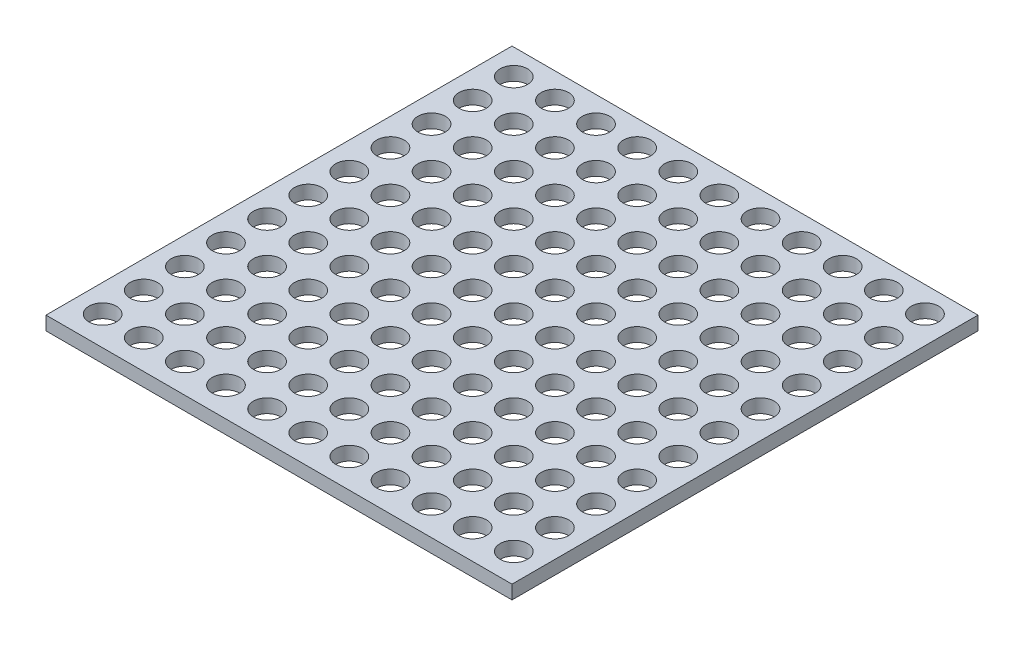
from build123d import *

# Parameters (mm, degrees)
SKETCH1_W           = 107.95
SKETCH1_H           = 107.95
SKETCH1_R           = 3.175
BOSS_EXTRUDE1_DEPTH = 3.175


with BuildPart() as part:
    # Sketch1 → Boss-Extrude1 (new body)
    with BuildSketch(Plane(origin=(0, 0, 0), x_dir=(1, 0, 0), z_dir=(0, 1, 0))):
        with Locations((53.975, 55.266525424)):
            Rectangle(SKETCH1_W, SKETCH1_H)
        with Locations((6.35, 8.056512099)):
            Circle(SKETCH1_R, mode=Mode.SUBTRACT)
        with Locations((15.875, 8.056512099)):
            Circle(SKETCH1_R, mode=Mode.SUBTRACT)
        with Locations((25.4, 8.056512099)):
            Circle(SKETCH1_R, mode=Mode.SUBTRACT)
        with Locations((34.925, 8.056512099)):
            Circle(SKETCH1_R, mode=Mode.SUBTRACT)
        with Locations((44.45, 8.056512099)):
            Circle(SKETCH1_R, mode=Mode.SUBTRACT)
        with Locations((53.975, 8.056512099)):
            Circle(SKETCH1_R, mode=Mode.SUBTRACT)
        with Locations((63.5, 8.056512099)):
            Circle(SKETCH1_R, mode=Mode.SUBTRACT)
        with Locations((73.025, 8.056512099)):
            Circle(SKETCH1_R, mode=Mode.SUBTRACT)
        with Locations((82.55, 8.056512099)):
            Circle(SKETCH1_R, mode=Mode.SUBTRACT)
        with Locations((92.075, 8.056512099)):
            Circle(SKETCH1_R, mode=Mode.SUBTRACT)
        with Locations((101.6, 8.056512099)):
            Circle(SKETCH1_R, mode=Mode.SUBTRACT)
        with Locations((101.6, 17.581512099)):
            Circle(SKETCH1_R, mode=Mode.SUBTRACT)
        with Locations((92.075, 17.581512099)):
            Circle(SKETCH1_R, mode=Mode.SUBTRACT)
        with Locations((82.55, 17.581512099)):
            Circle(SKETCH1_R, mode=Mode.SUBTRACT)
        with Locations((73.025, 17.581512099)):
            Circle(SKETCH1_R, mode=Mode.SUBTRACT)
        with Locations((63.5, 17.581512099)):
            Circle(SKETCH1_R, mode=Mode.SUBTRACT)
        with Locations((53.975, 17.581512099)):
            Circle(SKETCH1_R, mode=Mode.SUBTRACT)
        with Locations((44.45, 17.581512099)):
            Circle(SKETCH1_R, mode=Mode.SUBTRACT)
        with Locations((34.925, 17.581512099)):
            Circle(SKETCH1_R, mode=Mode.SUBTRACT)
        with Locations((25.4, 17.581512099)):
            Circle(SKETCH1_R, mode=Mode.SUBTRACT)
        with Locations((15.875, 17.581512099)):
            Circle(SKETCH1_R, mode=Mode.SUBTRACT)
        with Locations((6.35, 17.581512099)):
            Circle(SKETCH1_R, mode=Mode.SUBTRACT)
        with Locations((101.6, 27.106512099)):
            Circle(SKETCH1_R, mode=Mode.SUBTRACT)
        with Locations((92.075, 27.106512099)):
            Circle(SKETCH1_R, mode=Mode.SUBTRACT)
        with Locations((82.55, 27.106512099)):
            Circle(SKETCH1_R, mode=Mode.SUBTRACT)
        with Locations((73.025, 27.106512099)):
            Circle(SKETCH1_R, mode=Mode.SUBTRACT)
        with Locations((63.5, 27.106512099)):
            Circle(SKETCH1_R, mode=Mode.SUBTRACT)
        with Locations((53.975, 27.106512099)):
            Circle(SKETCH1_R, mode=Mode.SUBTRACT)
        with Locations((44.45, 27.106512099)):
            Circle(SKETCH1_R, mode=Mode.SUBTRACT)
        with Locations((34.925, 27.106512099)):
            Circle(SKETCH1_R, mode=Mode.SUBTRACT)
        with Locations((25.4, 27.106512099)):
            Circle(SKETCH1_R, mode=Mode.SUBTRACT)
        with Locations((15.875, 27.106512099)):
            Circle(SKETCH1_R, mode=Mode.SUBTRACT)
        with Locations((6.35, 27.106512099)):
            Circle(SKETCH1_R, mode=Mode.SUBTRACT)
        with Locations((101.6, 36.631512099)):
            Circle(SKETCH1_R, mode=Mode.SUBTRACT)
        with Locations((92.075, 36.631512099)):
            Circle(SKETCH1_R, mode=Mode.SUBTRACT)
        with Locations((82.55, 36.631512099)):
            Circle(SKETCH1_R, mode=Mode.SUBTRACT)
        with Locations((73.025, 36.631512099)):
            Circle(SKETCH1_R, mode=Mode.SUBTRACT)
        with Locations((63.5, 36.631512099)):
            Circle(SKETCH1_R, mode=Mode.SUBTRACT)
        with Locations((53.975, 36.631512099)):
            Circle(SKETCH1_R, mode=Mode.SUBTRACT)
        with Locations((44.45, 36.631512099)):
            Circle(SKETCH1_R, mode=Mode.SUBTRACT)
        with Locations((34.925, 36.631512099)):
            Circle(SKETCH1_R, mode=Mode.SUBTRACT)
        with Locations((25.4, 36.631512099)):
            Circle(SKETCH1_R, mode=Mode.SUBTRACT)
        with Locations((15.875, 36.631512099)):
            Circle(SKETCH1_R, mode=Mode.SUBTRACT)
        with Locations((6.35, 36.631512099)):
            Circle(SKETCH1_R, mode=Mode.SUBTRACT)
        with Locations((101.6, 46.156512099)):
            Circle(SKETCH1_R, mode=Mode.SUBTRACT)
        with Locations((92.075, 46.156512099)):
            Circle(SKETCH1_R, mode=Mode.SUBTRACT)
        with Locations((82.55, 46.156512099)):
            Circle(SKETCH1_R, mode=Mode.SUBTRACT)
        with Locations((73.025, 46.156512099)):
            Circle(SKETCH1_R, mode=Mode.SUBTRACT)
        with Locations((63.5, 46.156512099)):
            Circle(SKETCH1_R, mode=Mode.SUBTRACT)
        with Locations((53.975, 46.156512099)):
            Circle(SKETCH1_R, mode=Mode.SUBTRACT)
        with Locations((44.45, 46.156512099)):
            Circle(SKETCH1_R, mode=Mode.SUBTRACT)
        with Locations((34.925, 46.156512099)):
            Circle(SKETCH1_R, mode=Mode.SUBTRACT)
        with Locations((25.4, 46.156512099)):
            Circle(SKETCH1_R, mode=Mode.SUBTRACT)
        with Locations((15.875, 46.156512099)):
            Circle(SKETCH1_R, mode=Mode.SUBTRACT)
        with Locations((6.35, 46.156512099)):
            Circle(SKETCH1_R, mode=Mode.SUBTRACT)
        with Locations((101.6, 55.681512099)):
            Circle(SKETCH1_R, mode=Mode.SUBTRACT)
        with Locations((92.075, 55.681512099)):
            Circle(SKETCH1_R, mode=Mode.SUBTRACT)
        with Locations((82.55, 55.681512099)):
            Circle(SKETCH1_R, mode=Mode.SUBTRACT)
        with Locations((73.025, 55.681512099)):
            Circle(SKETCH1_R, mode=Mode.SUBTRACT)
        with Locations((63.5, 55.681512099)):
            Circle(SKETCH1_R, mode=Mode.SUBTRACT)
        with Locations((53.975, 55.681512099)):
            Circle(SKETCH1_R, mode=Mode.SUBTRACT)
        with Locations((44.45, 55.681512099)):
            Circle(SKETCH1_R, mode=Mode.SUBTRACT)
        with Locations((34.925, 55.681512099)):
            Circle(SKETCH1_R, mode=Mode.SUBTRACT)
        with Locations((25.4, 55.681512099)):
            Circle(SKETCH1_R, mode=Mode.SUBTRACT)
        with Locations((15.875, 55.681512099)):
            Circle(SKETCH1_R, mode=Mode.SUBTRACT)
        with Locations((6.35, 55.681512099)):
            Circle(SKETCH1_R, mode=Mode.SUBTRACT)
        with Locations((101.6, 65.206512099)):
            Circle(SKETCH1_R, mode=Mode.SUBTRACT)
        with Locations((92.075, 65.206512099)):
            Circle(SKETCH1_R, mode=Mode.SUBTRACT)
        with Locations((82.55, 65.206512099)):
            Circle(SKETCH1_R, mode=Mode.SUBTRACT)
        with Locations((73.025, 65.206512099)):
            Circle(SKETCH1_R, mode=Mode.SUBTRACT)
        with Locations((63.5, 65.206512099)):
            Circle(SKETCH1_R, mode=Mode.SUBTRACT)
        with Locations((53.975, 65.206512099)):
            Circle(SKETCH1_R, mode=Mode.SUBTRACT)
        with Locations((44.45, 65.206512099)):
            Circle(SKETCH1_R, mode=Mode.SUBTRACT)
        with Locations((34.925, 65.206512099)):
            Circle(SKETCH1_R, mode=Mode.SUBTRACT)
        with Locations((25.4, 65.206512099)):
            Circle(SKETCH1_R, mode=Mode.SUBTRACT)
        with Locations((15.875, 65.206512099)):
            Circle(SKETCH1_R, mode=Mode.SUBTRACT)
        with Locations((6.35, 65.206512099)):
            Circle(SKETCH1_R, mode=Mode.SUBTRACT)
        with Locations((101.6, 74.731512099)):
            Circle(SKETCH1_R, mode=Mode.SUBTRACT)
        with Locations((92.075, 74.731512099)):
            Circle(SKETCH1_R, mode=Mode.SUBTRACT)
        with Locations((82.55, 74.731512099)):
            Circle(SKETCH1_R, mode=Mode.SUBTRACT)
        with Locations((73.025, 74.731512099)):
            Circle(SKETCH1_R, mode=Mode.SUBTRACT)
        with Locations((63.5, 74.731512099)):
            Circle(SKETCH1_R, mode=Mode.SUBTRACT)
        with Locations((53.975, 74.731512099)):
            Circle(SKETCH1_R, mode=Mode.SUBTRACT)
        with Locations((44.45, 74.731512099)):
            Circle(SKETCH1_R, mode=Mode.SUBTRACT)
        with Locations((34.925, 74.731512099)):
            Circle(SKETCH1_R, mode=Mode.SUBTRACT)
        with Locations((25.4, 74.731512099)):
            Circle(SKETCH1_R, mode=Mode.SUBTRACT)
        with Locations((15.875, 74.731512099)):
            Circle(SKETCH1_R, mode=Mode.SUBTRACT)
        with Locations((6.35, 74.731512099)):
            Circle(SKETCH1_R, mode=Mode.SUBTRACT)
        with Locations((101.6, 84.256512099)):
            Circle(SKETCH1_R, mode=Mode.SUBTRACT)
        with Locations((92.075, 84.256512099)):
            Circle(SKETCH1_R, mode=Mode.SUBTRACT)
        with Locations((82.55, 84.256512099)):
            Circle(SKETCH1_R, mode=Mode.SUBTRACT)
        with Locations((73.025, 84.256512099)):
            Circle(SKETCH1_R, mode=Mode.SUBTRACT)
        with Locations((63.5, 84.256512099)):
            Circle(SKETCH1_R, mode=Mode.SUBTRACT)
        with Locations((53.975, 84.256512099)):
            Circle(SKETCH1_R, mode=Mode.SUBTRACT)
        with Locations((44.45, 84.256512099)):
            Circle(SKETCH1_R, mode=Mode.SUBTRACT)
        with Locations((34.925, 84.256512099)):
            Circle(SKETCH1_R, mode=Mode.SUBTRACT)
        with Locations((25.4, 84.256512099)):
            Circle(SKETCH1_R, mode=Mode.SUBTRACT)
        with Locations((15.875, 84.256512099)):
            Circle(SKETCH1_R, mode=Mode.SUBTRACT)
        with Locations((6.35, 84.256512099)):
            Circle(SKETCH1_R, mode=Mode.SUBTRACT)
        with Locations((101.6, 93.781512099)):
            Circle(SKETCH1_R, mode=Mode.SUBTRACT)
        with Locations((92.075, 93.781512099)):
            Circle(SKETCH1_R, mode=Mode.SUBTRACT)
        with Locations((82.55, 93.781512099)):
            Circle(SKETCH1_R, mode=Mode.SUBTRACT)
        with Locations((73.025, 93.781512099)):
            Circle(SKETCH1_R, mode=Mode.SUBTRACT)
        with Locations((63.5, 93.781512099)):
            Circle(SKETCH1_R, mode=Mode.SUBTRACT)
        with Locations((53.975, 93.781512099)):
            Circle(SKETCH1_R, mode=Mode.SUBTRACT)
        with Locations((44.45, 93.781512099)):
            Circle(SKETCH1_R, mode=Mode.SUBTRACT)
        with Locations((34.925, 93.781512099)):
            Circle(SKETCH1_R, mode=Mode.SUBTRACT)
        with Locations((25.4, 93.781512099)):
            Circle(SKETCH1_R, mode=Mode.SUBTRACT)
        with Locations((15.875, 93.781512099)):
            Circle(SKETCH1_R, mode=Mode.SUBTRACT)
        with Locations((6.35, 93.781512099)):
            Circle(SKETCH1_R, mode=Mode.SUBTRACT)
        with Locations((101.6, 103.306512099)):
            Circle(SKETCH1_R, mode=Mode.SUBTRACT)
        with Locations((92.075, 103.306512099)):
            Circle(SKETCH1_R, mode=Mode.SUBTRACT)
        with Locations((82.55, 103.306512099)):
            Circle(SKETCH1_R, mode=Mode.SUBTRACT)
        with Locations((73.025, 103.306512099)):
            Circle(SKETCH1_R, mode=Mode.SUBTRACT)
        with Locations((63.5, 103.306512099)):
            Circle(SKETCH1_R, mode=Mode.SUBTRACT)
        with Locations((53.975, 103.306512099)):
            Circle(SKETCH1_R, mode=Mode.SUBTRACT)
        with Locations((44.45, 103.306512099)):
            Circle(SKETCH1_R, mode=Mode.SUBTRACT)
        with Locations((34.925, 103.306512099)):
            Circle(SKETCH1_R, mode=Mode.SUBTRACT)
        with Locations((25.4, 103.306512099)):
            Circle(SKETCH1_R, mode=Mode.SUBTRACT)
        with Locations((15.875, 103.306512099)):
            Circle(SKETCH1_R, mode=Mode.SUBTRACT)
        with Locations((6.35, 103.306512099)):
            Circle(SKETCH1_R, mode=Mode.SUBTRACT)
    extrude(amount=BOSS_EXTRUDE1_DEPTH)


solid = part.part
